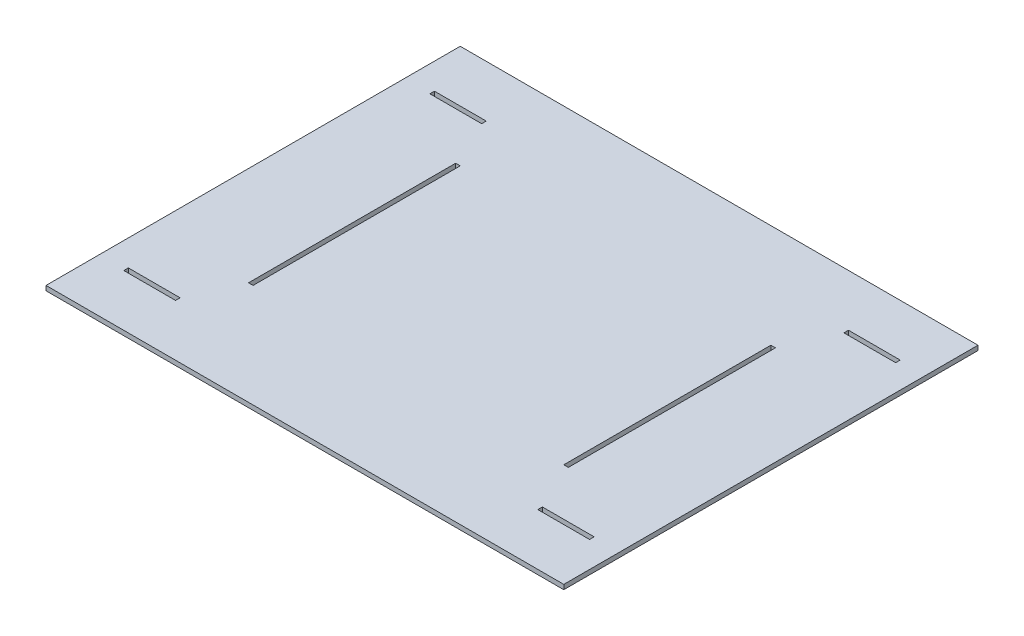
from build123d import *

# Parameters (mm, degrees)
SKETCH1_W                                  = 500
SKETCH1_H                                  = 400
BOSS_EXTRUDE1_DEPTH                        = 4.5
SKETCH2_W                                  = 4.4
SKETCH2_H                                  = 200
CUT_EXTRUDE1_DEPTH                         = 4.5
SKETCH5_W                                  = 50
SKETCH5_H                                  = 4.4
CUT_EXTRUDE2_DEPTH                         = 4.5
MIRROR5_AT_THE_SECOND_PLANE_COPY_1_SKETC_W = 50
MIRROR5_AT_THE_SECOND_PLANE_COPY_1_SKETC_H = 4.4
MIRROR5_AT_THE_SECOND_PLANE_COPY_1_DEPTH   = 4.5


with BuildPart() as part:
    # Sketch1 → Boss-Extrude1 (new body)
    with BuildSketch(Plane(origin=(0, 0, 0), x_dir=(1, 0, 0), z_dir=(0, 1, 0))):
        Rectangle(SKETCH1_W, SKETCH1_H)
    extrude(amount=BOSS_EXTRUDE1_DEPTH)

    # Sketch2 → Cut-Extrude1 (cut)
    with BuildSketch(Plane(origin=(0, 4.5, 0), x_dir=(1, 0, 0), z_dir=(0, 1, 0))):
        with Locations((-152.2, 0)):
            Rectangle(SKETCH2_W, SKETCH2_H)
    cut_extrude1 = extrude(amount=-CUT_EXTRUDE1_DEPTH, mode=Mode.SUBTRACT)

    # Mirror2: Cut-Extrude1 across plane
    add(cut_extrude1.mirror(Plane(origin=(0, 0, 0), x_dir=(0, 0, 1), z_dir=(1, 0, 0))), mode=Mode.SUBTRACT)

    # Sketch5 → Cut-Extrude2 (cut)
    with BuildSketch(Plane(origin=(0, 4.5, 0), x_dir=(1, 0, 0), z_dir=(0, 1, 0))):
        with Locations((-199.9, 147.8)):
            Rectangle(SKETCH5_W, SKETCH5_H)
    cut_extrude2 = extrude(amount=-CUT_EXTRUDE2_DEPTH, mode=Mode.SUBTRACT)

    # Mirror5: Cut-Extrude2 across plane
    add(cut_extrude2.mirror(Plane.XY), mode=Mode.SUBTRACT)

    # Mirror5 at the second plane: Cut-Extrude2 across plane
    add(cut_extrude2.mirror(Plane(origin=(0, 0, 0), x_dir=(0, 0, 1), z_dir=(1, 0, 0))), mode=Mode.SUBTRACT)

    # Mirror5 at the second plane copy 1 sketc → Mirror5 at the second plane copy 1 (cut)
    with BuildSketch(Plane(origin=(0, 4.5, 0), x_dir=(-1, 0, 0), z_dir=(0, 1, 0))):
        with Locations((-199.9, 147.8)):
            Rectangle(MIRROR5_AT_THE_SECOND_PLANE_COPY_1_SKETC_W, MIRROR5_AT_THE_SECOND_PLANE_COPY_1_SKETC_H)
    extrude(amount=-MIRROR5_AT_THE_SECOND_PLANE_COPY_1_DEPTH, mode=Mode.SUBTRACT)


solid = part.part
